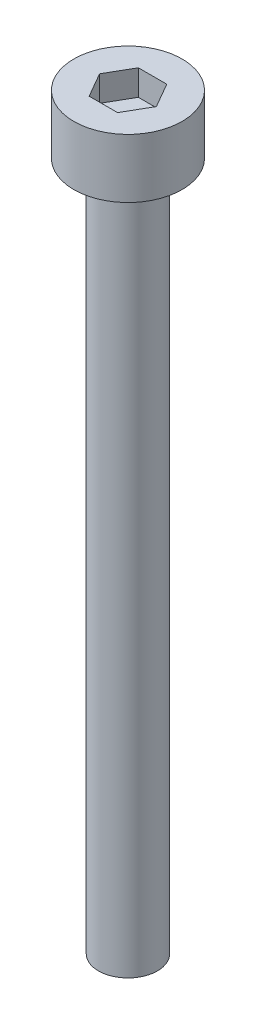
from build123d import *

# Parameters (mm, degrees)
SKETCH_1_R            = 2.75
EXTRUDE_248_DEPTH     = 3
CUT_EXTRUDE_378_DEPTH = 1.3
SKETCH_3_R            = 1.5
EXTRUDE_479_DEPTH     = 35


with BuildPart() as part:
    # 草图1 → Extrude 248 (new body)
    with BuildSketch(Plane(origin=(0, 0, 0), x_dir=(1, 0, 0), z_dir=(0, 1, 0))):
        Circle(SKETCH_1_R)
    extrude(amount=EXTRUDE_248_DEPTH)

    # 草图2 → Cut-Extrude 378 (cut)
    with BuildSketch(Plane(origin=(0, 3, 0), x_dir=(1, 0, 0), z_dir=(0, 1, 0))):
        Polygon((1.443375673, 0), (0.721687836, 1.25), (-0.721687836, 1.25), (-1.443375673, 0), (-0.721687836, -1.25), (0.721687836, -1.25), align=None)
    extrude(amount=-CUT_EXTRUDE_378_DEPTH, mode=Mode.SUBTRACT)

    # 草图3 → Extrude 479 (add)
    with BuildSketch(Plane.XZ):
        Circle(SKETCH_3_R)
    extrude(amount=EXTRUDE_479_DEPTH)


solid = part.part
